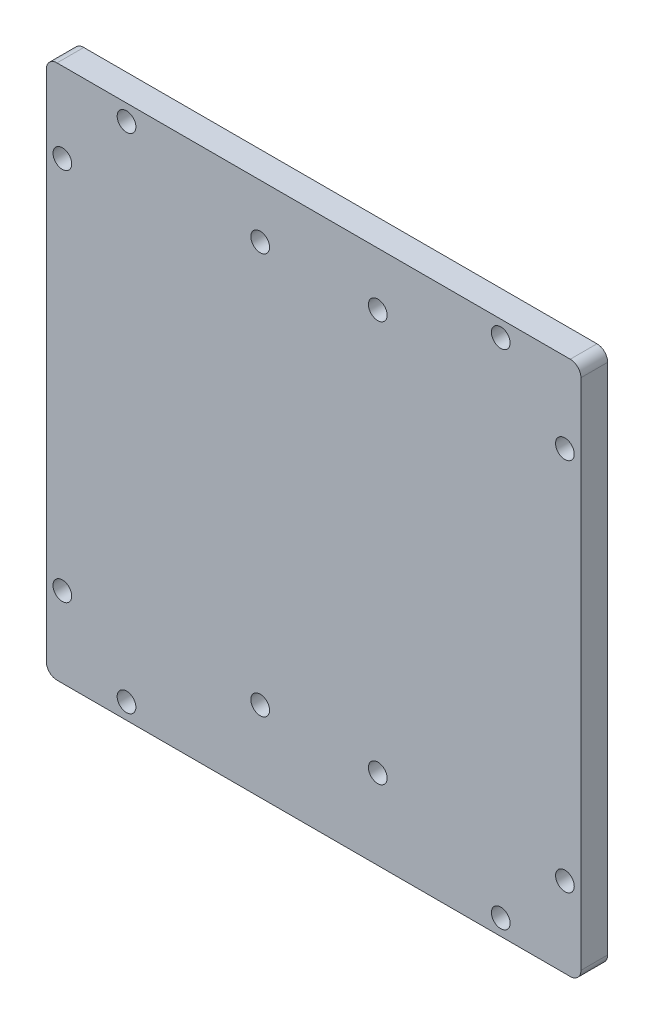
from build123d import *

# Parameters (mm, degrees)
SKETCH_1_R      = 1.75
EXTRUDE_1_DEPTH = 5


with BuildPart() as part:
    # Эскиз1 → Бобышка-Вытянуть1 (new body)
    with BuildSketch(Plane.XY):
        with BuildLine():
            Line((-48, -50), (48, -50))
            ThreePointArc((48, -50), (49.414213562, -49.414213562), (50, -48))
            Line((50, -48), (50, 48))
            ThreePointArc((50, 48), (49.414213562, 49.414213562), (48, 50))
            Line((48, 50), (-48, 50))
            ThreePointArc((-48, 50), (-49.414213562, 49.414213562), (-50, 48))
            Line((-50, 48), (-50, -48))
            ThreePointArc((-50, -48), (-49.414213562, -49.414213562), (-48, -50))
        make_face()
        with Locations((-47, 35)):
            Circle(SKETCH_1_R, mode=Mode.SUBTRACT)
        with Locations((47, 35)):
            Circle(SKETCH_1_R, mode=Mode.SUBTRACT)
        with Locations((47, -35)):
            Circle(SKETCH_1_R, mode=Mode.SUBTRACT)
        with Locations((-47, -35)):
            Circle(SKETCH_1_R, mode=Mode.SUBTRACT)
        with Locations((-35, 47)):
            Circle(SKETCH_1_R, mode=Mode.SUBTRACT)
        with Locations((35, 47)):
            Circle(SKETCH_1_R, mode=Mode.SUBTRACT)
        with Locations((-35, -47)):
            Circle(SKETCH_1_R, mode=Mode.SUBTRACT)
        with Locations((35, -47)):
            Circle(SKETCH_1_R, mode=Mode.SUBTRACT)
        with Locations((-10, 40)):
            Circle(SKETCH_1_R, mode=Mode.SUBTRACT)
        with Locations((12, 40)):
            Circle(SKETCH_1_R, mode=Mode.SUBTRACT)
        with Locations((-10, -35)):
            Circle(SKETCH_1_R, mode=Mode.SUBTRACT)
        with Locations((12, -35)):
            Circle(SKETCH_1_R, mode=Mode.SUBTRACT)
    extrude(amount=EXTRUDE_1_DEPTH)


solid = part.part
